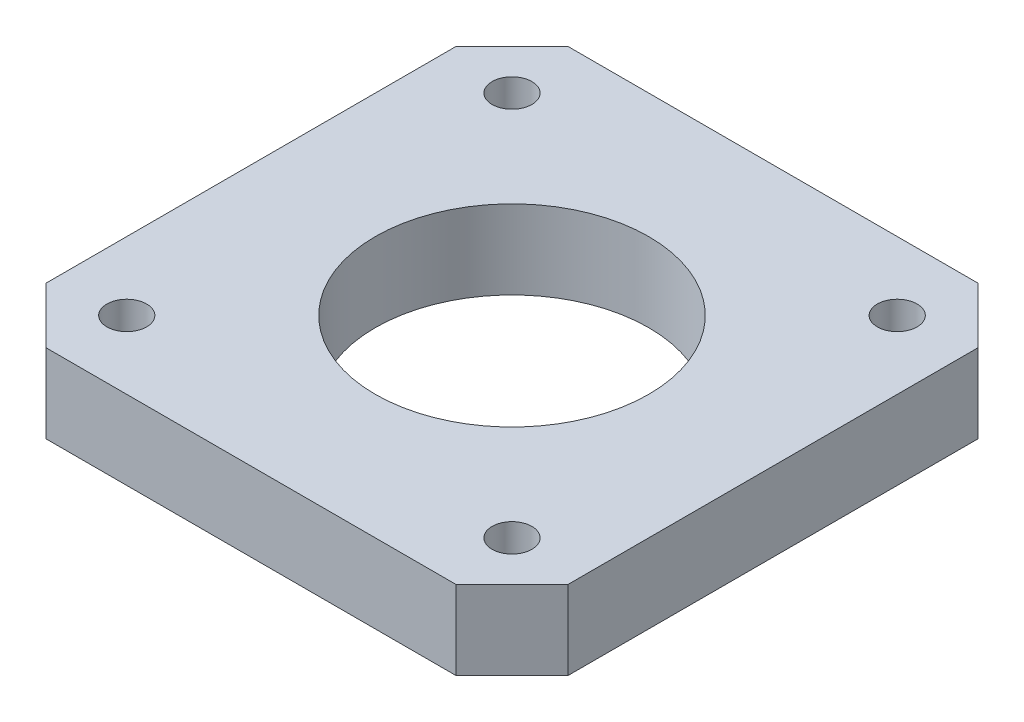
from build123d import *

# Parameters (mm, degrees)
SKETCH1_W            = 42
SKETCH1_H            = 42
BOSS_EXTRUDE1_DEPTH  = 6.35
CHAMFER1_SIZE        = 4.5
M3_CLEARANCE_HOLE1_D = 3.2
SKETCH6_R            = 11
CUT_EXTRUDE1_DEPTH   = 7.35


with BuildPart() as part:
    # Sketch1 → Boss-Extrude1 (new body)
    with BuildSketch(Plane(origin=(0, 0, 0), x_dir=(1, 0, 0), z_dir=(0, 1, 0))):
        Rectangle(SKETCH1_W, SKETCH1_H)
    extrude(amount=BOSS_EXTRUDE1_DEPTH)

    # Chamfer1
    chamfer1_edges = [part.edges().sort_by_distance(p)[0] for p in [
        (-21, 3.175, 21),
        (-21, 3.175, -21),
        (21, 3.175, -21),
        (21, 3.175, 21),
    ]]
    chamfer(chamfer1_edges, length=CHAMFER1_SIZE)

    # M3 Clearance Hole1 (through all)
    with Locations(Plane(origin=(0, 6.35, 0), x_dir=(1, 0, 0), z_dir=(0, 1, 0))):
        with Locations((-15.5, 15.5), (-15.5, -15.5), (15.5, -15.5), (15.5, 15.5)):
            Hole(M3_CLEARANCE_HOLE1_D / 2)

    # Sketch6 → Cut-Extrude1 (cut, through all)
    with BuildSketch(Plane(origin=(0, 6.35, 0), x_dir=(1, 0, 0), z_dir=(0, 1, 0))):
        Circle(SKETCH6_R)
    extrude(amount=-CUT_EXTRUDE1_DEPTH, mode=Mode.SUBTRACT)


solid = part.part
